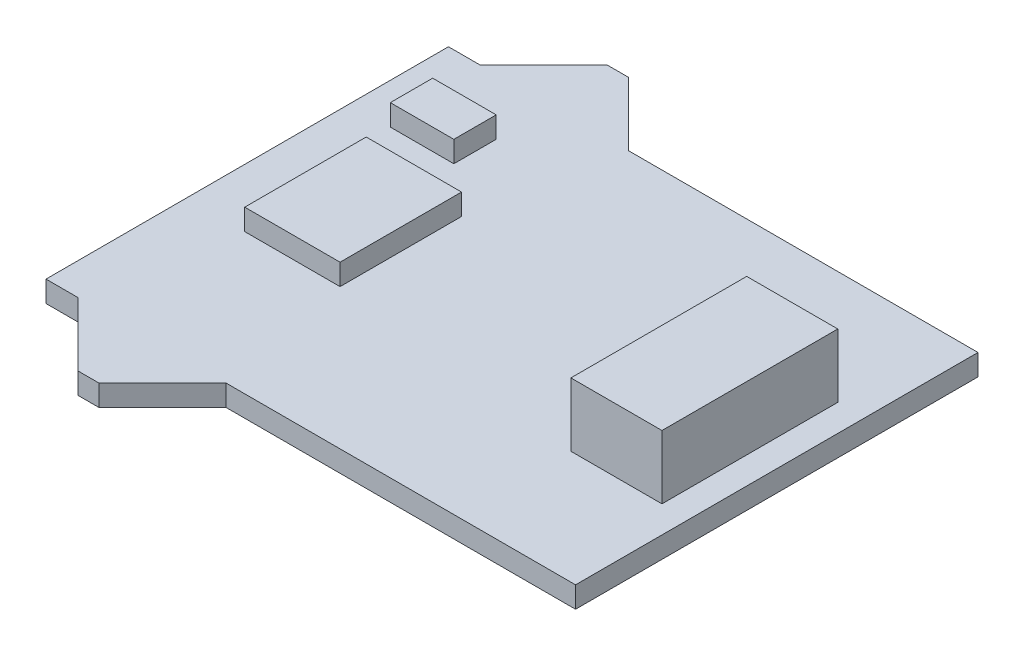
from build123d import *

# Parameters (mm, degrees)
BOSS_EXTRUDE1_DEPTH = 1.000000032
SKETCH2_W           = 4.49999989
SKETCH2_H           = 5.735208424
SKETCH2_W_2         = 3
SKETCH2_H_2         = 2
BOSS_EXTRUDE2_DEPTH = 1
SKETCH3_W           = 4.300000036
SKETCH3_H           = 8.29999991
BOSS_EXTRUDE3_DEPTH = 3.000000096


with BuildPart() as part:
    # Sketch1 → Boss-Extrude1 (new body)
    with BuildSketch(Plane(origin=(0, 0, 0), x_dir=(1, 0, 0), z_dir=(0, 1, 0))):
        Polygon((-3.499999985, 9.50000005), (-0.499999889, 12.500000146), (0.499999889, 12.500000146), (3.499999985, 9.50000005), (4.999999906, 9.50000005), (20.000000132, 9.50000005), (20.000000132, -9.50000005), (4.999999906, -9.50000005), (3.499999985, -9.50000005), (0.499999889, -12.500000146), (-0.499999889, -12.500000146), (-3.499999985, -9.50000005), (-4.999999906, -9.50000005), (-4.999999906, 9.50000005), align=None)
    extrude(amount=-BOSS_EXTRUDE1_DEPTH)

    # Sketch2 → Boss-Extrude2 (add)
    with BuildSketch(Plane(origin=(0, 0, 0), x_dir=(1, 0, 0), z_dir=(0, 1, 0))):
        Rectangle(SKETCH2_W, SKETCH2_H)
        with Locations((-1.5875, 5.842)):
            Rectangle(SKETCH2_W_2, SKETCH2_H_2)
    extrude(amount=BOSS_EXTRUDE2_DEPTH)

    # Sketch3 → Boss-Extrude3 (add)
    with BuildSketch(Plane(origin=(0, 0, 0), x_dir=(1, 0, 0), z_dir=(0, 1, 0))):
        with Locations((16.580000114, 0)):
            Rectangle(SKETCH3_W, SKETCH3_H)
    extrude(amount=BOSS_EXTRUDE3_DEPTH)


solid = part.part
